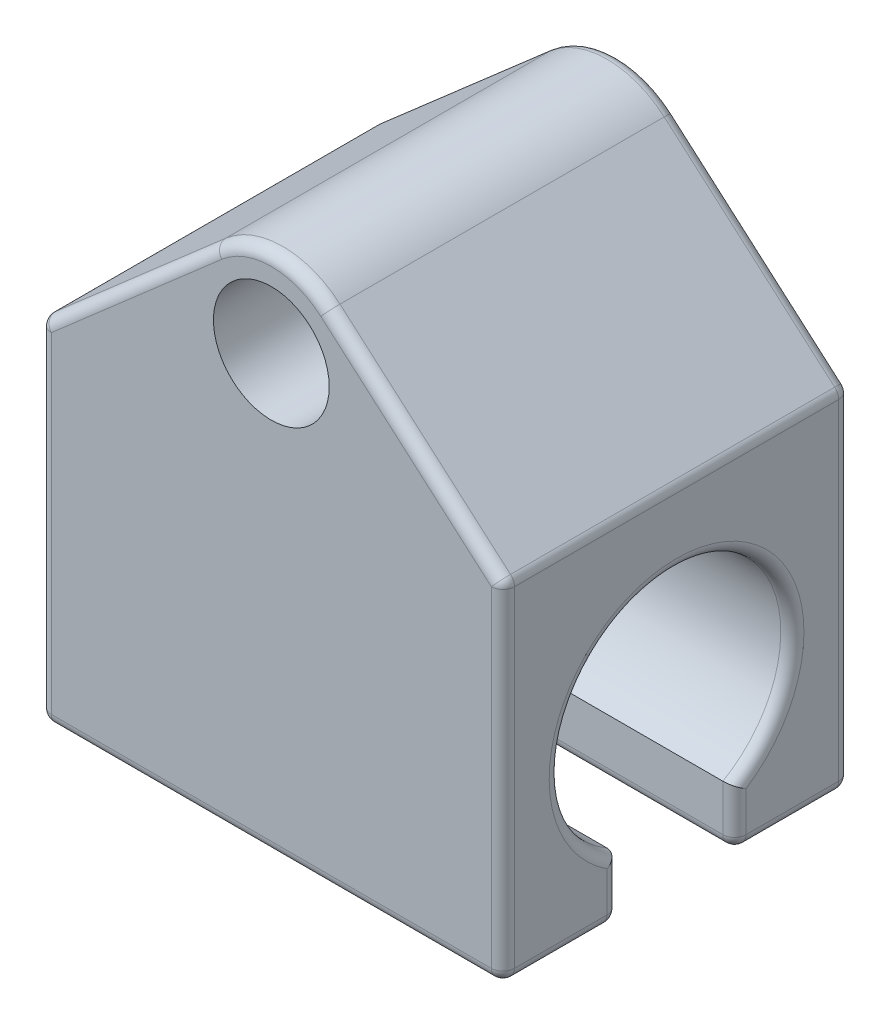
from build123d import *

# Parameters (mm, degrees)
BOSS_EXTRUDE1_DEPTH = 20
SKETCH3_R           = 5
BOSS_EXTRUDE2_DEPTH = 30
FILLET1_R           = 1


with BuildPart() as part:
    # Sketch1 → Boss-Extrude1 (new body, symmetric)
    with BuildSketch(Plane(origin=(0, 0, 0), x_dir=(0, 0, -1), z_dir=(1, 0, 0))):
        with BuildLine():
            Line((5, -8.660254038), (5, -13.660254038))
            Line((5, -13.660254038), (15, -13.660254038))
            Line((15, -13.660254038), (15, 16.339745962))
            Line((15, 16.339745962), (-15, 16.339745962))
            Line((-15, 16.339745962), (-15, -13.660254038))
            Line((-15, -13.660254038), (-5, -13.660254038))
            Line((-5, -13.660254038), (-5, -8.660254038))
            ThreePointArc((-5, -8.660254038), (0, 10), (5, -8.660254038))
        make_face()
    extrude(amount=BOSS_EXTRUDE1_DEPTH, both=True)

    # Sketch3 → Boss-Extrude2 (add)
    with BuildSketch(Plane.XY.offset(15)):
        with BuildLine():
            Line((-20, 16.339745962), (20, 16.339745962))
            Line((20, 16.339745962), (4.931506849, 29.490430894))
            ThreePointArc((4.931506849, 29.490430894), (0, 31.339745962), (-4.931506849, 29.490430894))
            Line((-4.931506849, 29.490430894), (-20, 16.339745962))
        make_face()
        with Locations((0, 23.839745962)):
            Circle(SKETCH3_R, mode=Mode.SUBTRACT)
    extrude(amount=-BOSS_EXTRUDE2_DEPTH)

    # Fillet1
    fillet1_edges = [part.edges().sort_by_distance(p)[0] for p in [
        (20, -13.660254038, -10),
        (-20, -11.160254038, -5),
        (-20, 10, 0),
        (20, 1.339745962, -15),
        (0, -13.660254038, 5),
        (0, -13.660254038, 15),
        (0, -13.660254038, -15),
        (0, -13.660254038, -5),
        (20, 16.339745962, 0),
        (20, 1.339745962, 15),
        (20, -13.660254038, 10),
        (-12.465753425, 22.915088428, 15),
        (12.465753425, 22.915088428, 15),
        (0, 31.339745962, 15),
        (20, -11.160254038, 5),
        (-12.465753425, 22.915088428, -15),
        (0, 31.339745962, -15),
        (12.465753425, 22.915088428, -15),
        (20, 10, 0),
        (20, -11.160254038, -5),
        (-20, -11.160254038, 5),
        (-20, -13.660254038, 10),
        (-20, 1.339745962, 15),
        (-20, 16.339745962, 0),
        (-20, 1.339745962, -15),
        (-20, -13.660254038, -10),
    ]]
    fillet(fillet1_edges, radius=FILLET1_R)


solid = part.part
